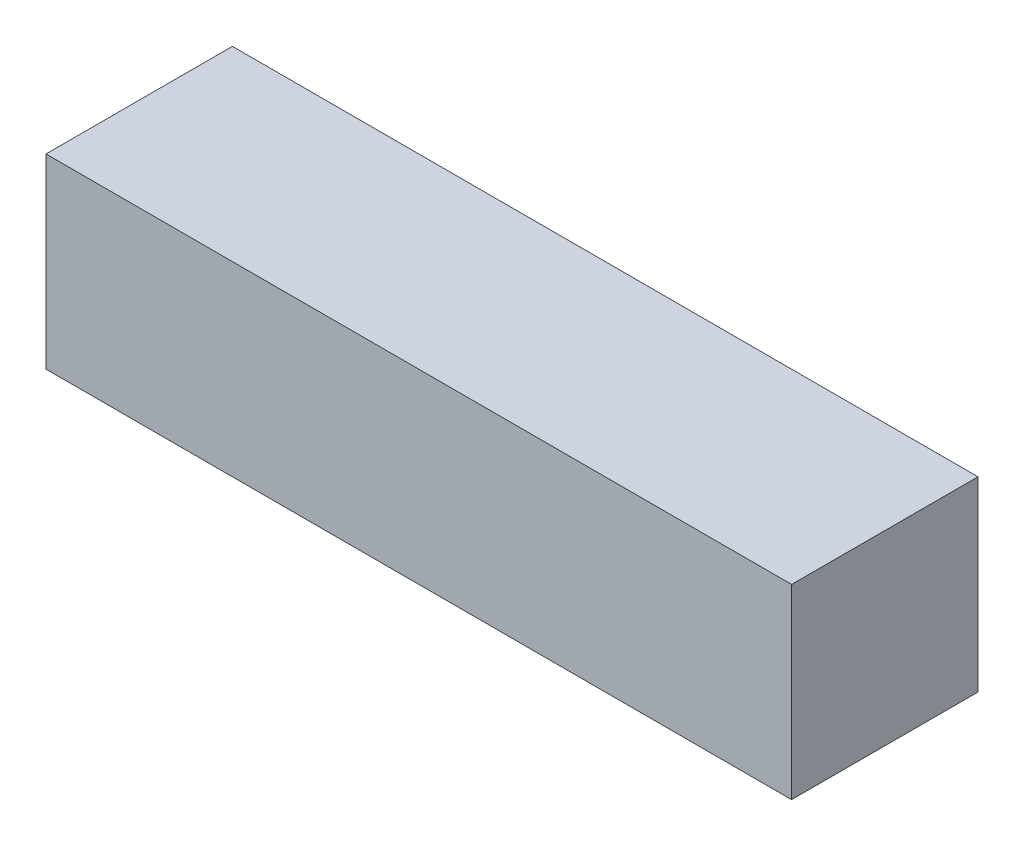
from build123d import *

# Parameters (mm, degrees)
SKETCH1_W           = 12.7
SKETCH1_H           = 3.175
BOSS_EXTRUDE1_DEPTH = 3.175


with BuildPart() as part:
    # Sketch1 → Boss-Extrude1 (new body)
    with BuildSketch(Plane.XY):
        with Locations((6.35, 1.5875)):
            Rectangle(SKETCH1_W, SKETCH1_H)
    extrude(amount=BOSS_EXTRUDE1_DEPTH)


solid = part.part
